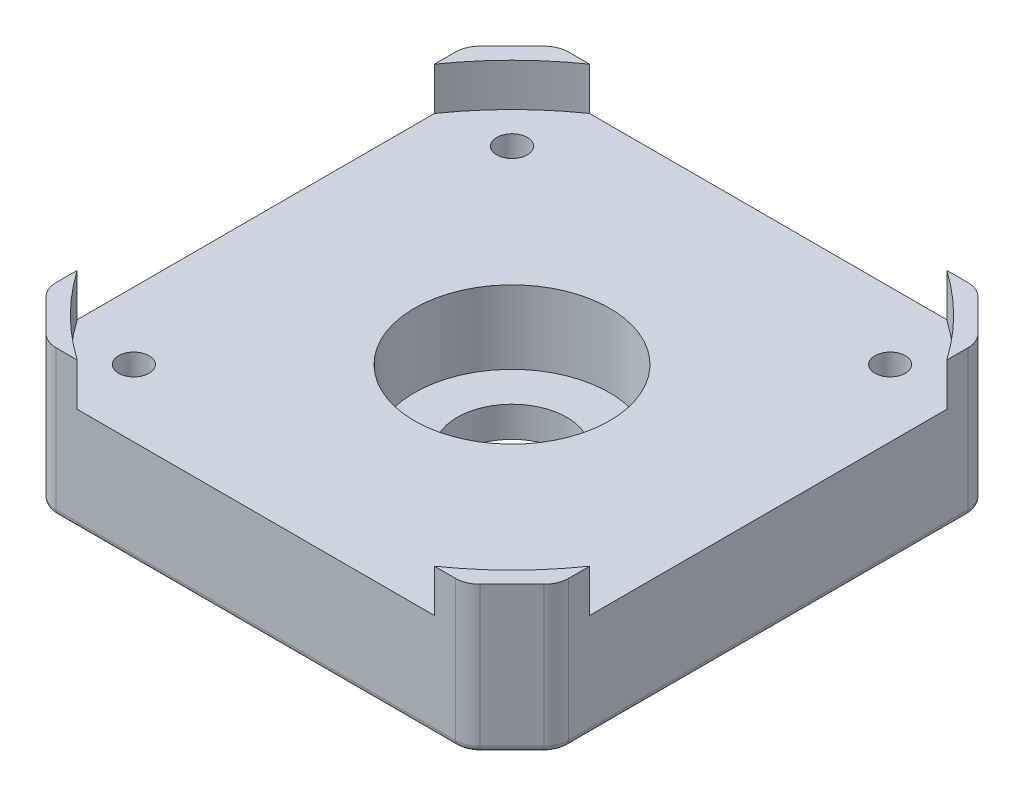
from build123d import *

# Parameters (mm, degrees)
SKETCH_1_R          = 4.5
SKETCH_1_R_2        = 1.25
EXTRUDE_1_DEPTH     = 8.5
EXTRUDE_2_DEPTH     = 12
CHAMFER_1_SIZE      = 2.5
SKETCH_2_R          = 8
CUT_EXTRUDE_1_DEPTH = 6
FILLET_1_R          = 2
FILLET_2_R          = 0.5


with BuildPart() as part:
    # Sketch 1 → Extrude 1 (new body)
    with BuildSketch(Plane(origin=(0, 0, 0), x_dir=(1, 0, 0), z_dir=(0, 1, 0))):
        with BuildLine():
            ThreePointArc((-14.641038215, 21), (-18.101933598, 18.101933598), (-21, 14.641038215))
            Line((-21, 14.641038215), (-21, -14.641038215))
            ThreePointArc((-21, -14.641038215), (-18.101933598, -18.101933598), (-14.641038215, -21))
            Line((-14.641038215, -21), (14.641038215, -21))
            ThreePointArc((14.641038215, -21), (18.101933598, -18.101933598), (21, -14.641038215))
            Line((21, -14.641038215), (21, 14.641038215))
            ThreePointArc((21, 14.641038215), (18.101933598, 18.101933598), (14.641038215, 21))
            Line((14.641038215, 21), (-14.641038215, 21))
        make_face()
        Circle(SKETCH_1_R, mode=Mode.SUBTRACT)
        with Locations((-15.5, 15.5)):
            Circle(SKETCH_1_R_2, mode=Mode.SUBTRACT)
        with Locations((15.5, 15.5)):
            Circle(SKETCH_1_R_2, mode=Mode.SUBTRACT)
        with Locations((15.5, -15.5)):
            Circle(SKETCH_1_R_2, mode=Mode.SUBTRACT)
        with Locations((-15.5, -15.5)):
            Circle(SKETCH_1_R_2, mode=Mode.SUBTRACT)
    extrude(amount=EXTRUDE_1_DEPTH)

    # Sketch 1_4 → Extrude 2 (add)
    with BuildSketch(Plane(origin=(0, 0, 0), x_dir=(1, 0, 0), z_dir=(0, 1, 0))):
        with BuildLine():
            ThreePointArc((21, -14.641038215), (18.101933598, -18.101933598), (14.641038215, -21))
            Line((14.641038215, -21), (17.2, -21))
            Line((17.2, -21), (21, -17.2))
            Line((21, -17.2), (21, -14.641038215))
        make_face()
        with BuildLine():
            ThreePointArc((-14.641038215, -21), (-18.101933598, -18.101933598), (-21, -14.641038215))
            Line((-21, -14.641038215), (-21, -17.2))
            Line((-21, -17.2), (-17.2, -21))
            Line((-17.2, -21), (-14.641038215, -21))
        make_face()
        with BuildLine():
            Line((-17.2, 21), (-21, 17.2))
            Line((-21, 17.2), (-21, 14.641038215))
            ThreePointArc((-21, 14.641038215), (-18.101933598, 18.101933598), (-14.641038215, 21))
            Line((-14.641038215, 21), (-17.2, 21))
        make_face()
        with BuildLine():
            Line((17.2, 21), (14.641038215, 21))
            ThreePointArc((14.641038215, 21), (18.101933598, 18.101933598), (21, 14.641038215))
            Line((21, 14.641038215), (21, 17.2))
            Line((21, 17.2), (17.2, 21))
        make_face()
    extrude(amount=EXTRUDE_2_DEPTH)

    # Chamfer 1
    chamfer_1_edges = [part.edges().sort_by_distance(p)[0] for p in [
        (-16.75, 0, 15.5),
        (14.25, 0, 15.5),
        (14.25, 0, -15.5),
        (-16.75, 0, -15.5),
    ]]
    chamfer(chamfer_1_edges, length=CHAMFER_1_SIZE)

    # Sketch 2 → Cut-Extrude 1 (cut)
    with BuildSketch(Plane(origin=(0, 8.5, 0), x_dir=(1, 0, 0), z_dir=(0, 1, 0))):
        Circle(SKETCH_2_R)
    extrude(amount=-CUT_EXTRUDE_1_DEPTH, mode=Mode.SUBTRACT)

    # Fillet 1
    fillet_1_edges = [part.edges().sort_by_distance(p)[0] for p in [
        (17.2, 6, 21),
        (21, 6, 17.2),
        (-21, 6, 17.2),
        (-17.2, 6, 21),
        (-17.2, 6, -21),
        (-21, 6, -17.2),
        (21, 6, -17.2),
        (17.2, 6, -21),
    ]]
    fillet(fillet_1_edges, radius=FILLET_1_R)

    # Fillet 2
    fillet_2_edges = [part.edges().sort_by_distance(p)[0] for p in [
        (21, 0, 0),
        (0, 0, 21),
        (-19.1, 0, 19.1),
        (-21, 0, 0),
        (-19.1, 0, -19.1),
        (0, 0, -21),
        (19.1, 0, -19.1),
        (19.1, 0, 19.1),
        (20.847759065, 0, -17.13693974),
        (17.13693974, 0, -20.847759065),
        (-17.13693974, 0, -20.847759065),
        (-20.847759065, 0, -17.13693974),
        (-20.847759065, 0, 17.13693974),
        (-17.13693974, 0, 20.847759065),
        (17.13693974, 0, 20.847759065),
        (20.847759065, 0, 17.13693974),
    ]]
    fillet(fillet_2_edges, radius=FILLET_2_R)


solid = part.part
